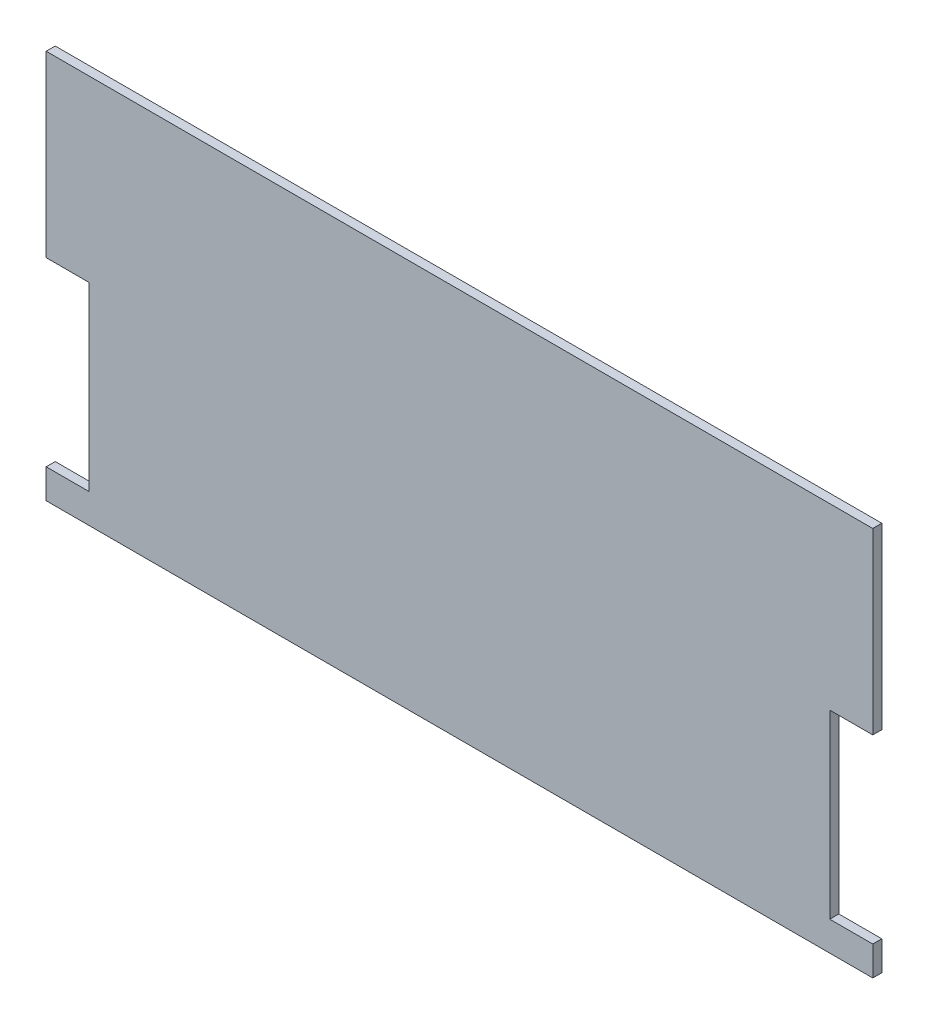
from build123d import *

# Parameters (mm, degrees)
BOSS_EXTRUDE1_DEPTH = 2


with BuildPart() as part:
    # Sketch1 → Boss-Extrude1 (new body)
    with BuildSketch(Plane.XY):
        Polygon((0, -79.5), (0, -86), (182.6, -86), (182.6, -79.5), (173.1, -79.5), (173.1, -39.5), (182.6, -39.5), (182.6, 0), (0, 0), (0, -39.5), (9.5, -39.5), (9.5, -79.5), align=None)
    extrude(amount=BOSS_EXTRUDE1_DEPTH)


solid = part.part
